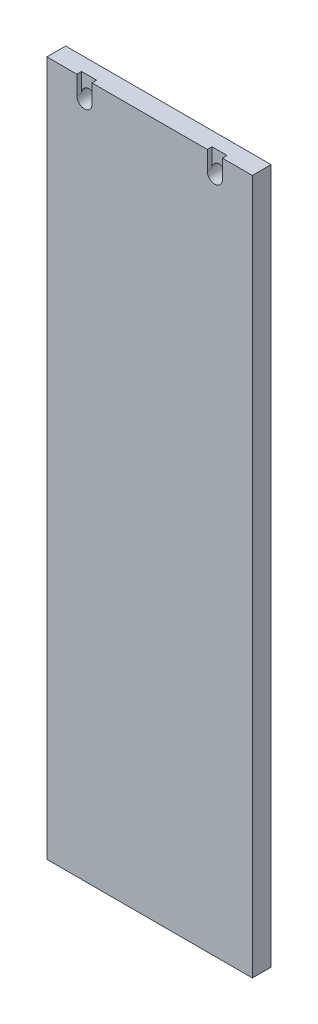
from build123d import *

# Parameters (mm, degrees)
BOSS_EXTRUDE1_DEPTH    = 6.35
F_10_CLEARANCE_HOLE1_D = 5.1054
CUT_EXTRUDE1_DEPTH     = 1.5875


with BuildPart() as part:
    # Sketch1 → Boss-Extrude1 (new body)
    with BuildSketch(Plane.XY):
        Polygon((0, 15.875), (0, -206.525), (69.5, -206.525), (69.5, 15.875), (69.5, 28.575), (0, 28.575), align=None)
    extrude(amount=-BOSS_EXTRUDE1_DEPTH)

    # #10 Clearance Hole1 (through all)
    with Locations(Plane.XY):
        with Locations((12.7, 22.225), (56.8, 22.225)):
            Hole(F_10_CLEARANCE_HOLE1_D / 2)

    # Sketch6 → Cut-Extrude1 (cut)
    with BuildSketch(Plane(origin=(0, 0, 0), x_dir=(-1, 0, 0), z_dir=(0, 0, -1))):
        with BuildLine():
            Line((-59.3527, 22.225), (-59.3527, 28.575))
            Line((-59.3527, 28.575), (-54.2473, 28.575))
            Line((-54.2473, 28.575), (-54.2473, 22.225))
            ThreePointArc((-54.2473, 22.225), (-56.8, 19.6723), (-59.3527, 22.225))
        make_face()
        with BuildLine():
            Line((-10.1473, 22.225), (-10.1473, 28.575))
            Line((-10.1473, 28.575), (-15.2527, 28.575))
            Line((-15.2527, 28.575), (-15.2527, 22.225))
            ThreePointArc((-15.2527, 22.225), (-12.7, 19.6723), (-10.1473, 22.225))
        make_face()
    extrude(amount=CUT_EXTRUDE1_DEPTH, mode=Mode.SUBTRACT)


solid = part.part
